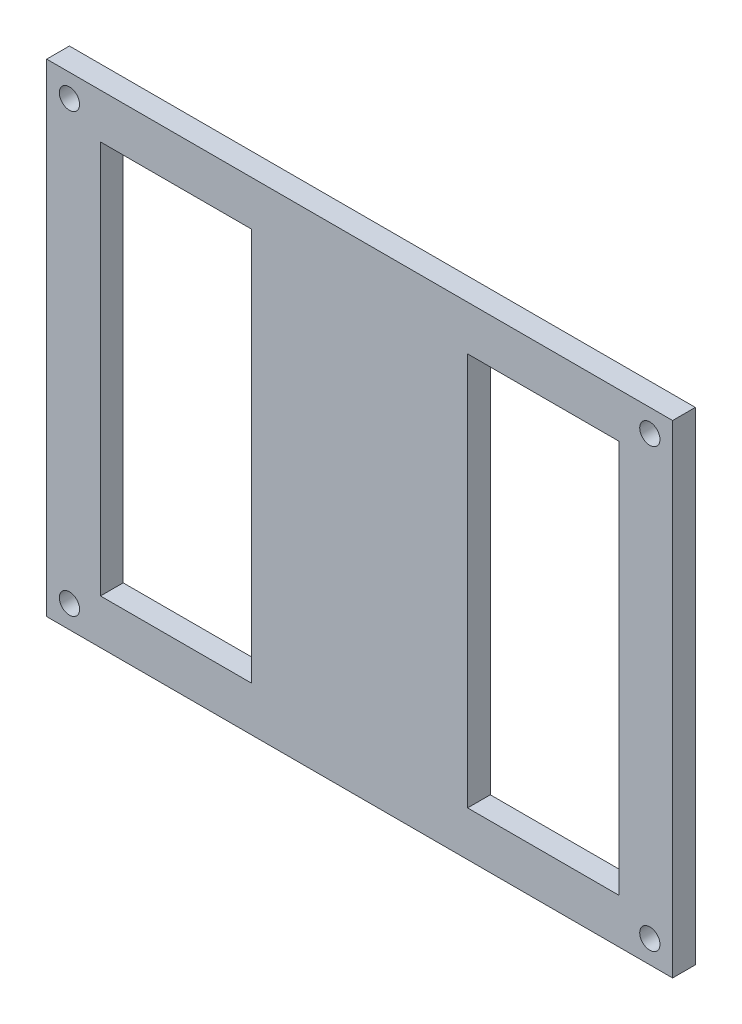
from build123d import *

# Parameters (mm, degrees)
SKETCH1_W           = 100
SKETCH1_H           = 80
BOSS_EXTRUDE1_DEPTH = 3.175
SKETCH4_W           = 100.51
SKETCH4_H           = 80.51
SKETCH4_W_2         = 87.47
SKETCH4_H_2         = 67.47
CUT_EXTRUDE3_DEPTH  = 10
SKETCH5_R           = 1.415
CUT_EXTRUDE4_DEPTH  = 10
SKETCH2_W           = 21.13
SKETCH2_H           = 65.13
CUT_EXTRUDE5_DEPTH  = 10
BOSS_EXTRUDE2_DEPTH = 3.175


with BuildPart() as part:
    # Sketch1 → Boss-Extrude1 (new body)
    with BuildSketch(Plane.XY):
        Rectangle(SKETCH1_W, SKETCH1_H)
    extrude(amount=BOSS_EXTRUDE1_DEPTH)

    # Sketch4 → Cut-Extrude3 (cut)
    with BuildSketch(Plane.XY.offset(3.175)):
        Rectangle(SKETCH4_W, SKETCH4_H)
        Rectangle(SKETCH4_W_2, SKETCH4_H_2, mode=Mode.SUBTRACT)
    extrude(amount=-CUT_EXTRUDE3_DEPTH, mode=Mode.SUBTRACT)

    # Sketch5 → Cut-Extrude4 (cut)
    with BuildSketch(Plane.XY.offset(3.175)):
        with Locations((-40.553019485, 30.553019485)):
            Circle(SKETCH5_R)
        with Locations((-40.553019485, -30.553019485)):
            Circle(SKETCH5_R)
        with Locations((40.553019485, -30.553019485)):
            Circle(SKETCH5_R)
        with Locations((40.553019485, 30.553019485)):
            Circle(SKETCH5_R)
    extrude(amount=-CUT_EXTRUDE4_DEPTH, mode=Mode.SUBTRACT)

    # Sketch2 → Cut-Extrude5 (cut)
    with BuildSketch(Plane.XY.offset(3.175)):
        with Locations((-25.65, 0)):
            Rectangle(SKETCH2_W, SKETCH2_H)
        with Locations((25.65, 0)):
            Rectangle(SKETCH2_W, SKETCH2_H)
    extrude(amount=-CUT_EXTRUDE5_DEPTH, mode=Mode.SUBTRACT)

    # Sketch6 → Boss-Extrude2 (add)
    with BuildSketch(Plane.XY.offset(3.175)):
        Polygon((-25.65, -32.565), (-15.085, -32.565), (-15.085, -27.475), (-25.65, -27.475), (-36.215, -27.475), (-36.215, -32.565), align=None)
        Polygon((25.65, -32.565), (36.215, -32.565), (36.215, -27.475), (25.65, -27.475), (15.085, -27.475), (15.085, -32.565), align=None)
        Polygon((15.085, 27.475), (15.085, 32.565), (25.65, 32.565), (36.215, 32.565), (36.215, 27.475), (25.65, 27.475), align=None)
        Polygon((-36.215, 27.475), (-36.215, 32.565), (-25.65, 32.565), (-15.085, 32.565), (-15.085, 27.475), (-25.65, 27.475), align=None)
    extrude(amount=-BOSS_EXTRUDE2_DEPTH)


solid = part.part
